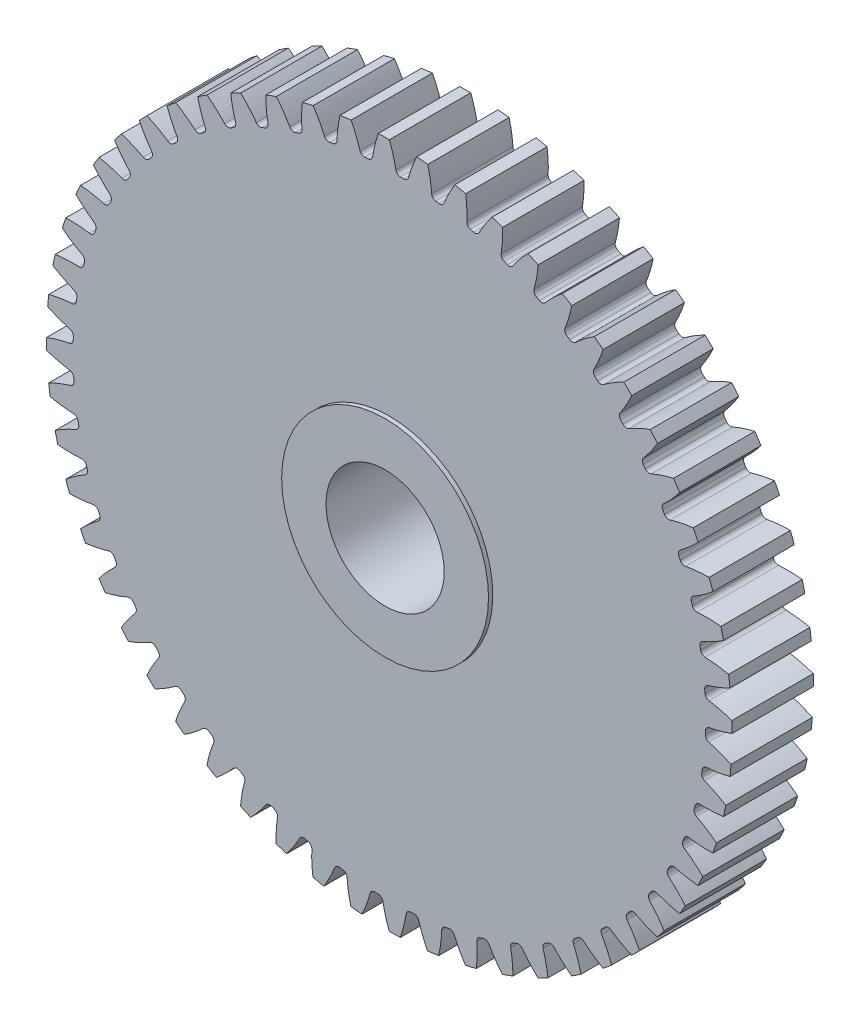
from build123d import *

# Parameters (mm, degrees)
SKETCH3_R           = 36.83
GEARBODY_DEPTH      = 8.7376
TOOTHCUT_DEPTH      = 53.81328861
CIRPATTERN1_COUNT   = 56
BOREDIA_R           = 6.35
BORE_DEPTH          = 12700
SKETCH4_R           = 11.1125
SKETCH4_R_2         = 6.35
BOSS_EXTRUDE1_DEPTH = 0.4572
SKETCH5_R           = 11.1125
SKETCH5_R_2         = 6.35
BOSS_EXTRUDE2_DEPTH = 0.4572


with BuildPart() as part:
    # Sketch3 → gearBody (new body)
    with BuildSketch(Plane.XY):
        Circle(SKETCH3_R)
    extrude(amount=GEARBODY_DEPTH)

    # Sketch2 → toothCut (cut, through all)
    with BuildSketch(Plane.XY):
        with BuildLine():
            ThreePointArc((33.949706813, -1.552812403), (33.957853024, -1.363098314), (33.964939104, -1.173341671))
            ThreePointArc((33.964939104, -1.173341671), (34.085641609, -0.864776515), (34.372974773, -0.699788022))
            ThreePointArc((34.372974773, -0.699788022), (39.510371111, 1.35349126), (43.46337325, 5.224223882))
            ThreePointArc((43.46337325, 5.224223882), (43.740993221, -1.755802232), (42.90479906, -8.691118859))
            ThreePointArc((42.90479906, -8.691118859), (39.274764673, -4.515996431), (34.318473101, -2.057547571))
            ThreePointArc((34.318473101, -2.057547571), (34.045288663, -1.870059404), (33.949706813, -1.552812403))
        make_face()
    toothcut = extrude(amount=TOOTHCUT_DEPTH, mode=Mode.SUBTRACT)

    # CirPattern1: toothCut ×56 about axis
    cirpattern1_axis = Axis((0, 0, 0), (0, 0, 1))
    for i in range(1, CIRPATTERN1_COUNT):
        add(toothcut.rotate(cirpattern1_axis, i * 360 / CIRPATTERN1_COUNT), mode=Mode.SUBTRACT)

    # boreDia → bore (cut, symmetric)
    with BuildSketch(Plane.XY):
        Circle(BOREDIA_R)
    extrude(amount=BORE_DEPTH, both=True, mode=Mode.SUBTRACT)

    # Sketch4 → Boss-Extrude1 (add)
    with BuildSketch(Plane(origin=(0, 0, 0), x_dir=(-1, 0, 0), z_dir=(0, 0, -1))):
        with Locations(Location((0, 0, 0), (0, 0, 180))):
            Circle(SKETCH4_R)
        with Locations(Location((0, 0, 0), (0, 0, 180))):
            Circle(SKETCH4_R_2, mode=Mode.SUBTRACT)
    extrude(amount=BOSS_EXTRUDE1_DEPTH)

    # Sketch5 → Boss-Extrude2 (add)
    with BuildSketch(Plane.XY.offset(8.7376)):
        Circle(SKETCH5_R)
        Circle(SKETCH5_R_2, mode=Mode.SUBTRACT)
    extrude(amount=BOSS_EXTRUDE2_DEPTH)


solid = part.part
